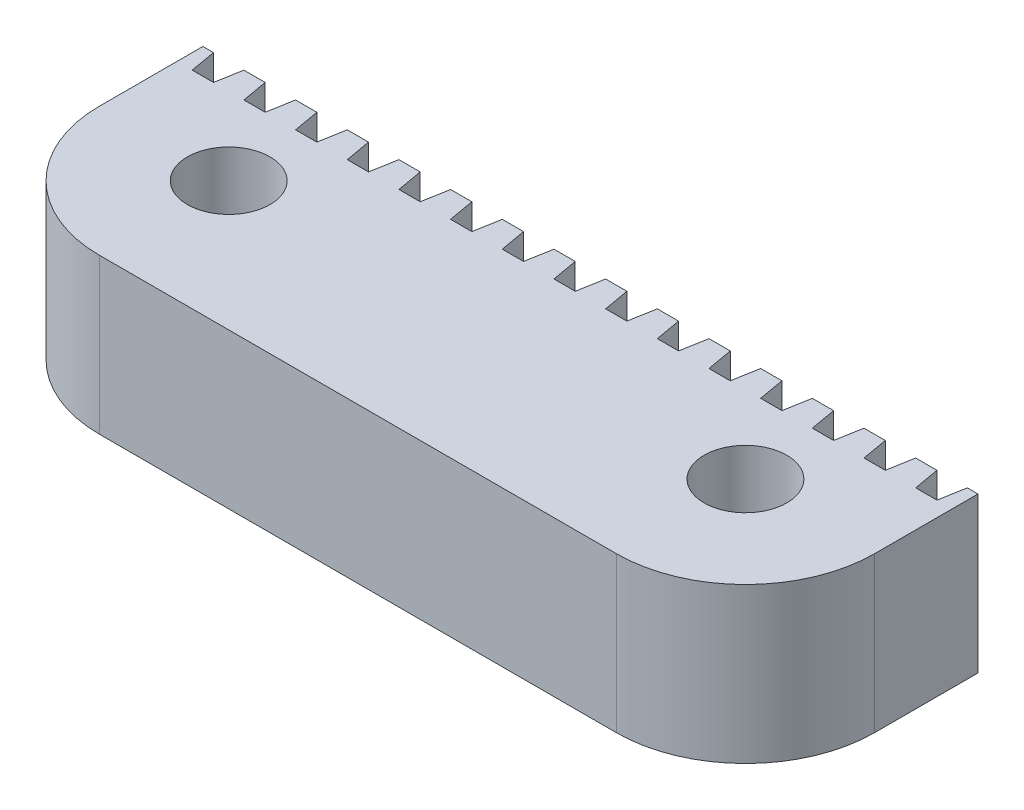
from build123d import *

# Parameters (mm, degrees)
SKETCH1_W            = 30
SKETCH1_H            = 9
BOSS_EXTRUDE1_DEPTH  = 6
CUT_EXTRUDE1_DEPTH   = 7
LPATTERN2_COUNT      = 8
LPATTERN2_PITCH      = 2
LPATTERN2_COL_COUNT  = 8
LPATTERN2_COL_PITCH  = 2
M3_CLEARANCE_HOLE1_D = 3.2
FILLET1_R            = 5


with BuildPart() as part:
    # Sketch1 → Boss-Extrude1 (new body)
    with BuildSketch(Plane(origin=(0, 0, 0), x_dir=(1, 0, 0), z_dir=(0, 1, 0))):
        with Locations((15, 4.5)):
            Rectangle(SKETCH1_W, SKETCH1_H)
    extrude(amount=BOSS_EXTRUDE1_DEPTH)

    # Sketch2 → Cut-Extrude1 (cut, through all)
    with BuildSketch(Plane(origin=(0, 6, 0), x_dir=(1, 0, 0), z_dir=(0, 1, 0))):
        Polygon((14.41183651, 9), (15.58816349, 9), (15.41183651, 8), (14.58816349, 8), align=None)
    cut_extrude1 = extrude(amount=-CUT_EXTRUDE1_DEPTH, mode=Mode.SUBTRACT)

    # LPattern2: Cut-Extrude1 ×8
    with Locations(*[(-i * LPATTERN2_PITCH, 0, 0) for i in range(1, LPATTERN2_COUNT)]):
        add(cut_extrude1, mode=Mode.SUBTRACT)

    # LPattern2 col: Cut-Extrude1 ×8
    with Locations(*[(i * LPATTERN2_COL_PITCH, 0, 0) for i in range(1, LPATTERN2_COL_COUNT)]):
        add(cut_extrude1, mode=Mode.SUBTRACT)

    # M3 Clearance Hole1 (through all)
    with Locations(Plane(origin=(0, 6, 0), x_dir=(1, 0, 0), z_dir=(0, 1, 0))):
        with Locations((5, 5), (25, 5)):
            Hole(M3_CLEARANCE_HOLE1_D / 2)

    # Fillet1
    fillet1_edges = [part.edges().sort_by_distance(p)[0] for p in [
        (30, 3, 0),
        (0, 3, 0),
    ]]
    fillet(fillet1_edges, radius=FILLET1_R)


solid = part.part
